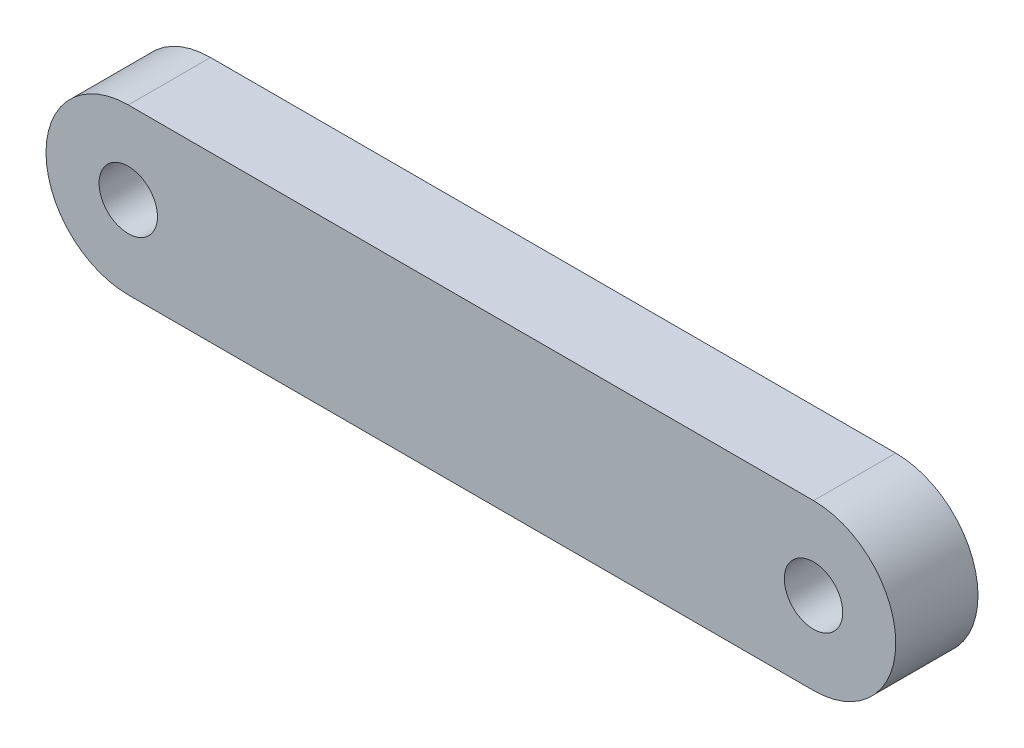
from build123d import *

# Parameters (mm, degrees)
SKETCH1_R           = 0.8875
BOSS_EXTRUDE1_DEPTH = 2.5


with BuildPart() as part:
    # Sketch1 → Boss-Extrude1 (new body)
    with BuildSketch(Plane.XY):
        with BuildLine():
            Line((-10.415, 2.5), (10.415, 2.5))
            ThreePointArc((10.415, 2.5), (12.915, 0), (10.415, -2.5))
            Line((10.415, -2.5), (-10.415, -2.5))
            ThreePointArc((-10.415, -2.5), (-12.915, 0), (-10.415, 2.5))
        make_face()
        with Locations((-10.415, 0)):
            Circle(SKETCH1_R, mode=Mode.SUBTRACT)
        with Locations((10.415, 0)):
            Circle(SKETCH1_R, mode=Mode.SUBTRACT)
    extrude(amount=BOSS_EXTRUDE1_DEPTH)


solid = part.part
